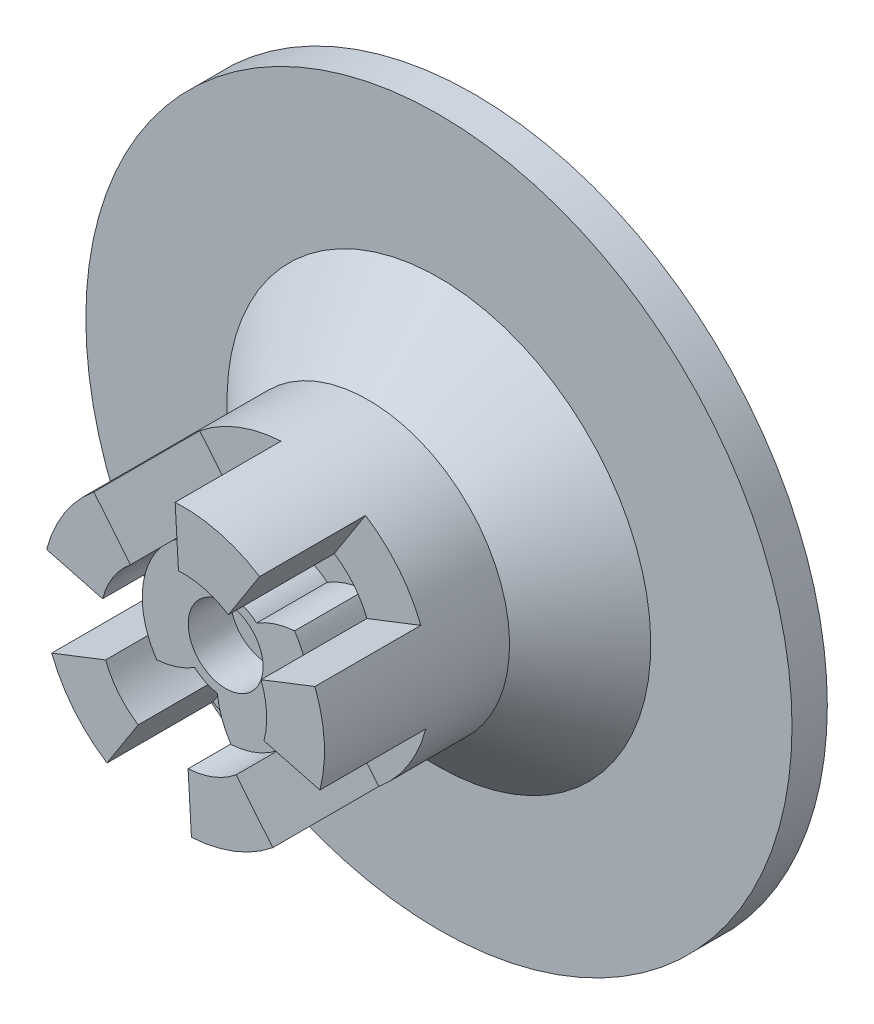
from build123d import *

# Parameters (mm, degrees)
SKETCH11_R          = 3.3672
CUT_EXTRUDE5_DEPTH  = 3.81
SKETCH11_5_R        = 3.3672
CUT_EXTRUDE7_DEPTH  = 7.62
CUT_EXTRUDE8_DEPTH  = 10.16
SKETCH13_R          = 6.35
CUT_EXTRUDE10_DEPTH = 12.192
CHAMFER1_SIZE       = 3.81
CHAMFER2_SIZE       = 6.35
CUT_EXTRUDE11_DEPTH = 9.525


with BuildPart() as part:
    # Sketch2 → Revolve1 (revolve)
    with BuildSketch(Plane(origin=(0, 0, 0), x_dir=(0, 0, -1), z_dir=(1, 0, 0))):
        Polygon((-13.081, 0), (-13.081, 9.525), (-13.081, 12.7), (-9.906, 12.7), (9.906, 12.7), (9.906, 31.75), (13.081, 31.75), (13.081, 0), align=None)
    revolve(axis=Axis((0, 0, -13.081), (0, 0, 1)))

    # Sketch11 → Cut-Extrude5 (cut)
    with BuildSketch(Plane.XY.offset(13.081)):
        with BuildLine():
            ThreePointArc((-6.195622147, -4.226614037), (-3.288572679, -6.740570431), (0.482036294, -7.48449337))
            ThreePointArc((0.482036294, -7.48449337), (-0.337099755, -5.872751112), (-0.749008883, -4.112345522))
            ThreePointArc((-0.749008883, -4.112345522), (-1.832831173, -3.756744587), (-2.78016744, -3.121388955))
            ThreePointArc((-2.78016744, -3.121388955), (-4.421160263, -3.880229865), (-6.195622147, -4.226614037))
        make_face()
        with BuildLine():
            ThreePointArc((7.5, 0), (7.166490288, 2.211654799), (6.195622147, 4.226614037))
            ThreePointArc((6.195622147, 4.226614037), (4.421160263, 3.880229865), (2.78016744, 3.121388955))
            ThreePointArc((2.78016744, 3.121388955), (1.832831173, 3.756744587), (0.749008883, 4.112345522))
            ThreePointArc((0.749008883, 4.112345522), (0.337099755, 5.872751112), (-0.482036294, 7.48449337))
            ThreePointArc((-0.482036294, 7.48449337), (-6.740570431, 3.288572679), (-6.195622147, -4.226614037))
            ThreePointArc((-6.195622147, -4.226614037), (-4.421160263, -3.880229865), (-2.78016744, -3.121388955))
            ThreePointArc((-2.78016744, -3.121388955), (-1.832831173, -3.756744587), (-0.749008883, -4.112345522))
            ThreePointArc((-0.749008883, -4.112345522), (-0.337099755, -5.872751112), (0.482036294, -7.48449337))
            ThreePointArc((0.482036294, -7.48449337), (5.471072665, -5.130045214), (7.5, 0))
        make_face()
        Circle(SKETCH11_R, mode=Mode.SUBTRACT)
        Circle(SKETCH11_R)
        with BuildLine():
            ThreePointArc((2.78016744, 3.121388955), (4.421160263, 3.880229865), (6.195622147, 4.226614037))
            ThreePointArc((6.195622147, 4.226614037), (3.288572679, 6.740570431), (-0.482036294, 7.48449337))
            ThreePointArc((-0.482036294, 7.48449337), (0.337099755, 5.872751112), (0.749008883, 4.112345522))
            ThreePointArc((0.749008883, 4.112345522), (1.832831173, 3.756744587), (2.78016744, 3.121388955))
        make_face()
    extrude(amount=-CUT_EXTRUDE5_DEPTH, mode=Mode.SUBTRACT)

    # Sketch11_5 → Cut-Extrude7 (cut)
    with BuildSketch(Plane.XY.offset(13.081)):
        Circle(SKETCH11_5_R)
    extrude(amount=-CUT_EXTRUDE7_DEPTH, mode=Mode.SUBTRACT)

    # Sketch11_6 → Cut-Extrude8 (cut)
    with BuildSketch(Plane.XY.offset(13.081)):
        with BuildLine():
            ThreePointArc((-6.195622147, -4.226614037), (-3.288572679, -6.740570431), (0.482036294, -7.48449337))
            ThreePointArc((0.482036294, -7.48449337), (-0.337099755, -5.872751112), (-0.749008883, -4.112345522))
            ThreePointArc((-0.749008883, -4.112345522), (-1.832831173, -3.756744587), (-2.78016744, -3.121388955))
            ThreePointArc((-2.78016744, -3.121388955), (-4.421160263, -3.880229865), (-6.195622147, -4.226614037))
        make_face()
        with BuildLine():
            ThreePointArc((2.78016744, 3.121388955), (4.421160263, 3.880229865), (6.195622147, 4.226614037))
            ThreePointArc((6.195622147, 4.226614037), (3.288572679, 6.740570431), (-0.482036294, 7.48449337))
            ThreePointArc((-0.482036294, 7.48449337), (0.337099755, 5.872751112), (0.749008883, 4.112345522))
            ThreePointArc((0.749008883, 4.112345522), (1.832831173, 3.756744587), (2.78016744, 3.121388955))
        make_face()
    extrude(amount=-CUT_EXTRUDE8_DEPTH, mode=Mode.SUBTRACT)

    # Sketch13 → Cut-Extrude10 (cut)
    with BuildSketch(Plane(origin=(0, 0, -13.081), x_dir=(-1, 0, 0), z_dir=(0, 0, -1))):
        Circle(SKETCH13_R)
    extrude(amount=-CUT_EXTRUDE10_DEPTH, mode=Mode.SUBTRACT)

    # Chamfer1
    chamfer1_edges = [part.edges().sort_by_distance(p)[0] for p in [
        (6.35, 0, -0.889),
    ]]
    chamfer(chamfer1_edges, length=CHAMFER1_SIZE)

    # Chamfer2
    chamfer2_edges = [part.edges().sort_by_distance(p)[0] for p in [
        (0, -12.7, -9.906),
    ]]
    chamfer(chamfer2_edges, length=CHAMFER2_SIZE)

    # Sketch14 → Cut-Extrude11 (cut)
    with BuildSketch(Plane.XY.offset(13.081)):
        with BuildLine():
            Line((-7.254714263, 1.902398741), (-12.284649485, 3.221395201))
            ThreePointArc((-12.284649485, 3.221395201), (-12.678861805, -0.732436563), (-11.831978794, -4.614572333))
            Line((-11.831978794, -4.614572333), (-6.987389052, -2.725141142))
            ThreePointArc((-6.987389052, -2.725141142), (-7.487516814, -0.432541277), (-7.254714263, 1.902398741))
        make_face()
        with BuildLine():
            ThreePointArc((-0.732436563, 12.678861805), (-4.614572333, 11.831978794), (-8.045001612, 9.82689926))
            Line((-8.045001612, 9.82689926), (-4.750985204, 5.803286965))
            ThreePointArc((-4.750985204, 5.803286965), (-2.725141142, 6.987389052), (-0.432541277, 7.487516814))
            Line((-0.432541277, 7.487516814), (-0.732436563, 12.678861805))
        make_face()
        with BuildLine():
            ThreePointArc((11.831978794, 4.614572333), (9.82689926, 8.045001612), (6.859894358, 10.68793008))
            Line((6.859894358, 10.68793008), (4.051118716, 6.311769732))
            ThreePointArc((4.051118716, 6.311769732), (5.803286965, 4.750985204), (6.987389052, 2.725141142))
            Line((6.987389052, 2.725141142), (11.831978794, 4.614572333))
        make_face()
        with BuildLine():
            Line((4.750985204, -5.803286965), (8.045001612, -9.82689926))
            ThreePointArc((8.045001612, -9.82689926), (10.68793008, -6.859894358), (12.284649485, -3.221395201))
            Line((12.284649485, -3.221395201), (7.254714263, -1.902398741))
            ThreePointArc((7.254714263, -1.902398741), (6.311769732, -4.051118716), (4.750985204, -5.803286965))
        make_face()
        with BuildLine():
            Line((-4.051118716, -6.311769732), (-6.859894358, -10.68793008))
            ThreePointArc((-6.859894358, -10.68793008), (-3.221395201, -12.284649485), (0.732436563, -12.678861805))
            Line((0.732436563, -12.678861805), (0.432541277, -7.487516814))
            ThreePointArc((0.432541277, -7.487516814), (-1.902398741, -7.254714263), (-4.051118716, -6.311769732))
        make_face()
    extrude(amount=-CUT_EXTRUDE11_DEPTH, mode=Mode.SUBTRACT)


solid = part.part
